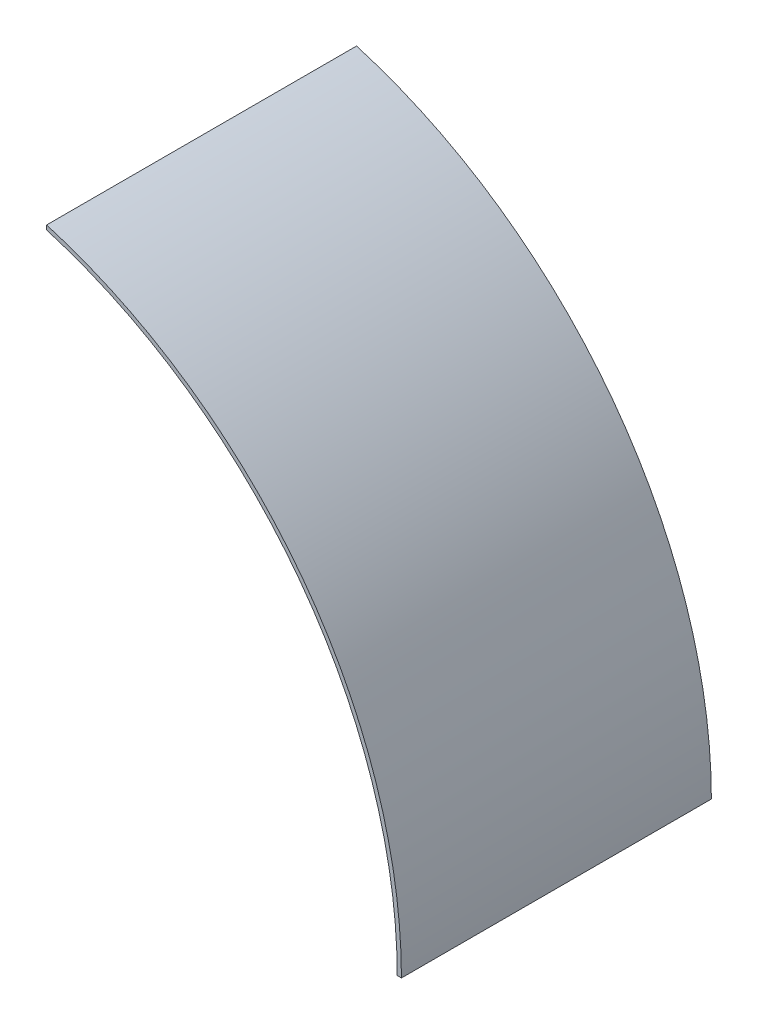
from build123d import *

# Parameters (mm, degrees)
INNER_RING_RIGHT_SIDE_DEPTH = 112.268


with BuildPart() as part:
    # Sketch2 → Inner Ring - Right Side (new body)
    with BuildSketch(Plane.XY):
        with BuildLine():
            Line((50.8, 171.972774211), (50.8, 170.388379885))
            ThreePointArc((50.8, 170.388379885), (142.557146436, 106.25582337), (177.8, 0))
            Line((177.8, 0), (179.31892, 0))
            ThreePointArc((179.31892, 0), (143.639611887, 107.344943835), (50.8, 171.972774211))
        make_face()
    extrude(amount=INNER_RING_RIGHT_SIDE_DEPTH)


solid = part.part
